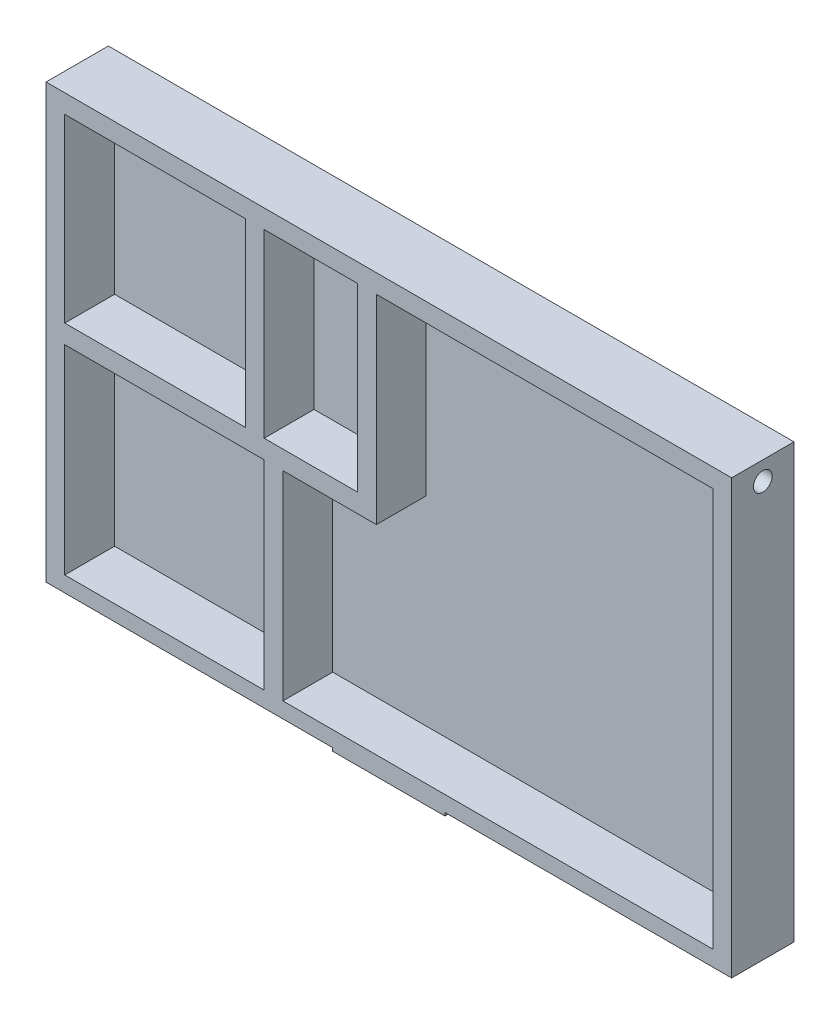
from build123d import *

# Parameters (mm, degrees)
SKETCH1_W           = 110
SKETCH1_H           = 70
BOSS_EXTRUDE1_DEPTH = 10
SKETCH2_W           = 29
SKETCH2_H           = 29
SKETCH2_W_2         = 32
SKETCH2_H_2         = 32
SKETCH2_W_3         = 15
CUT_EXTRUDE1_DEPTH  = 8
CUT_EXTRUDE3_DEPTH  = 8
SKETCH4_R           = 1.5
CUT_EXTRUDE4_DEPTH  = 2.5
SKETCH5_W           = 46
SKETCH5_H           = 0.5
CUT_EXTRUDE5_DEPTH  = 11
SKETCH7_W           = 18
SKETCH7_H           = 2
BOSS_EXTRUDE2_DEPTH = 3


with BuildPart() as part:
    # Sketch1 → Boss-Extrude1 (new body)
    with BuildSketch(Plane.XY):
        Rectangle(SKETCH1_W, SKETCH1_H)
    extrude(amount=BOSS_EXTRUDE1_DEPTH)

    # Sketch2 → Cut-Extrude1 (cut)
    with BuildSketch(Plane.XY.offset(10)):
        with Locations((-37.5, 17.5)):
            Rectangle(SKETCH2_W, SKETCH2_H)
        with Locations((-36, -16)):
            Rectangle(SKETCH2_W_2, SKETCH2_H_2)
        with Locations((-12.5, 17.5)):
            Rectangle(SKETCH2_W_3, SKETCH2_H)
    extrude(amount=-CUT_EXTRUDE1_DEPTH, mode=Mode.SUBTRACT)

    # Sketch3 → Cut-Extrude3 (cut)
    with BuildSketch(Plane.XY.offset(10)):
        Polygon((-17, 0), (-17, -32), (52, -32), (52, 32), (-2, 32), (-2, 0), align=None)
    extrude(amount=-CUT_EXTRUDE3_DEPTH, mode=Mode.SUBTRACT)

    # Sketch4 → Cut-Extrude4 (cut)
    with BuildSketch(Plane.ZY.offset(55)):
        with Locations((5, 32)):
            Circle(SKETCH4_R)
    cut_extrude4 = extrude(amount=-CUT_EXTRUDE4_DEPTH, mode=Mode.SUBTRACT)

    # Mirror1: Cut-Extrude4 across plane
    add(cut_extrude4.mirror(Plane.ZY), mode=Mode.SUBTRACT)

    # Sketch5 → Cut-Extrude5 (cut, through all)
    with BuildSketch(Plane.XY.offset(10)):
        with Locations((-32, -34.75)):
            Rectangle(SKETCH5_W, SKETCH5_H)
        with Locations((32, -34.75)):
            Rectangle(SKETCH5_W, SKETCH5_H)
    extrude(amount=-CUT_EXTRUDE5_DEPTH, mode=Mode.SUBTRACT)

    # Sketch7 → Boss-Extrude2 (add)
    with BuildSketch(Plane.XZ.offset(35)):
        with Locations((0, 1)):
            Rectangle(SKETCH7_W, SKETCH7_H)
    extrude(amount=BOSS_EXTRUDE2_DEPTH)


solid = part.part
